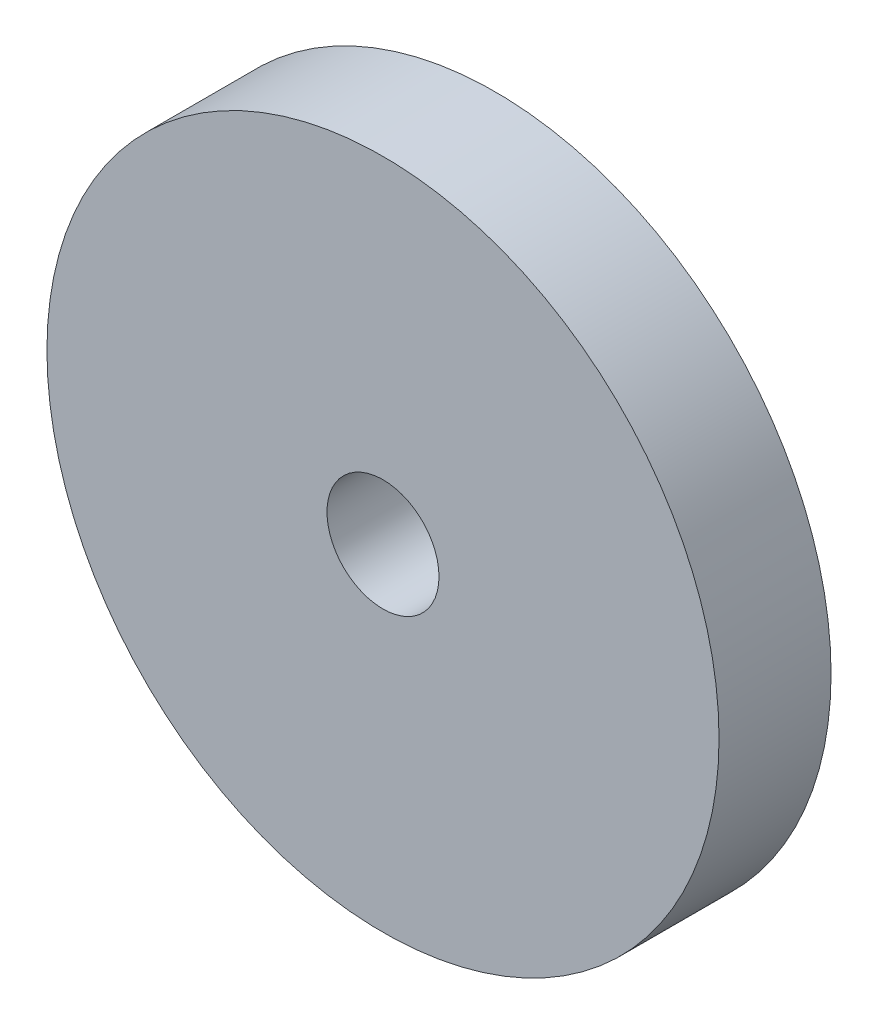
from build123d import *

# Parameters (mm, degrees)
SKETCH1_R           = 60
BOSS_EXTRUDE2_DEPTH = 20
SKETCH2_R           = 10
CUT_EXTRUDE1_DEPTH  = 21


with BuildPart() as part:
    # Sketch1 → Boss-Extrude2 (new body)
    with BuildSketch(Plane.XY):
        Circle(SKETCH1_R)
    extrude(amount=BOSS_EXTRUDE2_DEPTH)

    # Sketch2 → Cut-Extrude1 (cut, through all)
    with BuildSketch(Plane.XY.offset(20)):
        Circle(SKETCH2_R)
    extrude(amount=-CUT_EXTRUDE1_DEPTH, mode=Mode.SUBTRACT)


solid = part.part
